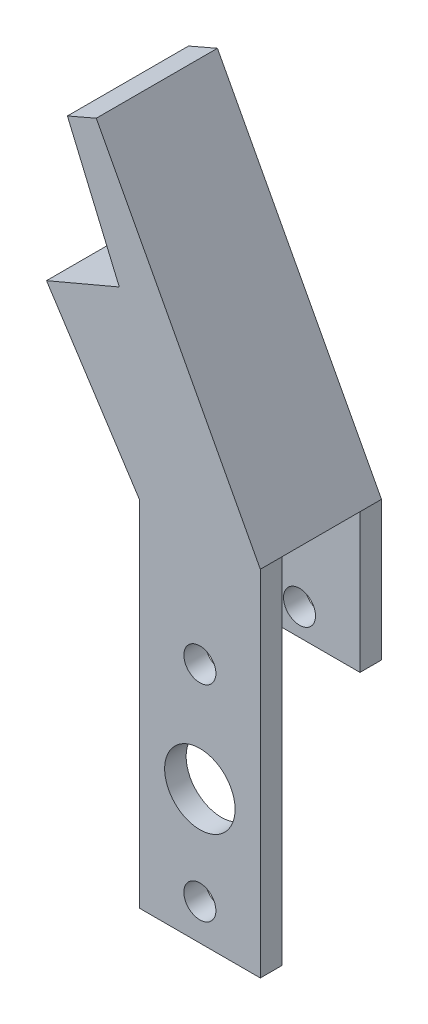
from build123d import *

# Parameters (mm, degrees)
BOSS_EXTRUDE2_DEPTH = 14.3256
SKETCH3_W           = 9.2456
SKETCH3_H           = 41.8592
CUT_EXTRUDE1_DEPTH  = 14.3256
SKETCH5_W           = 2.54
SKETCH5_H           = 25.4
CUT_EXTRUDE2_DEPTH  = 14.3256
SKETCH6_R           = 1.8923
SKETCH6_R_2         = 4.1656
CUT_EXTRUDE3_DEPTH  = 14.3256


with BuildPart() as part:
    # Sketch1 → Boss-Extrude2 (new body)
    with BuildSketch(Plane.XY):
        Polygon((-1.591692429, -17.789476976), (12.708507571, -17.789476976), (12.708507571, 24.069723024), (-6.692780338, 60.558238657), (-10.104996335, 59.08528636), (-3.971611665, 44.635937574), (-12.575754632, 40.98369557), (-1.591692429, 24.069723024), align=None)
    extrude(amount=BOSS_EXTRUDE2_DEPTH)

    # Sketch3 → Cut-Extrude1 (cut)
    with BuildSketch(Plane(origin=(12.708507571, 0, 0), x_dir=(0, 0, -1), z_dir=(1, 0, 0))):
        with Locations((-7.1628, 3.140123024)):
            Rectangle(SKETCH3_W, SKETCH3_H)
    extrude(amount=-CUT_EXTRUDE1_DEPTH, mode=Mode.SUBTRACT)

    # Sketch5 → Cut-Extrude2 (cut)
    with BuildSketch(Plane(origin=(12.708507571, 0, 0), x_dir=(0, 0, -1), z_dir=(1, 0, 0))):
        with Locations((-1.27, -5.089476976)):
            Rectangle(SKETCH5_W, SKETCH5_H)
    extrude(amount=-CUT_EXTRUDE2_DEPTH, mode=Mode.SUBTRACT)

    # Sketch6 → Cut-Extrude3 (cut)
    with BuildSketch(Plane.XY.offset(14.3256)):
        with Locations((5.558407571, -13.522276976)):
            Circle(SKETCH6_R)
        with Locations((5.558407571, 10.760123024)):
            Circle(SKETCH6_R)
        with Locations((5.558407571, -2.016076976)):
            Circle(SKETCH6_R_2)
    extrude(amount=-CUT_EXTRUDE3_DEPTH, mode=Mode.SUBTRACT)


solid = part.part
